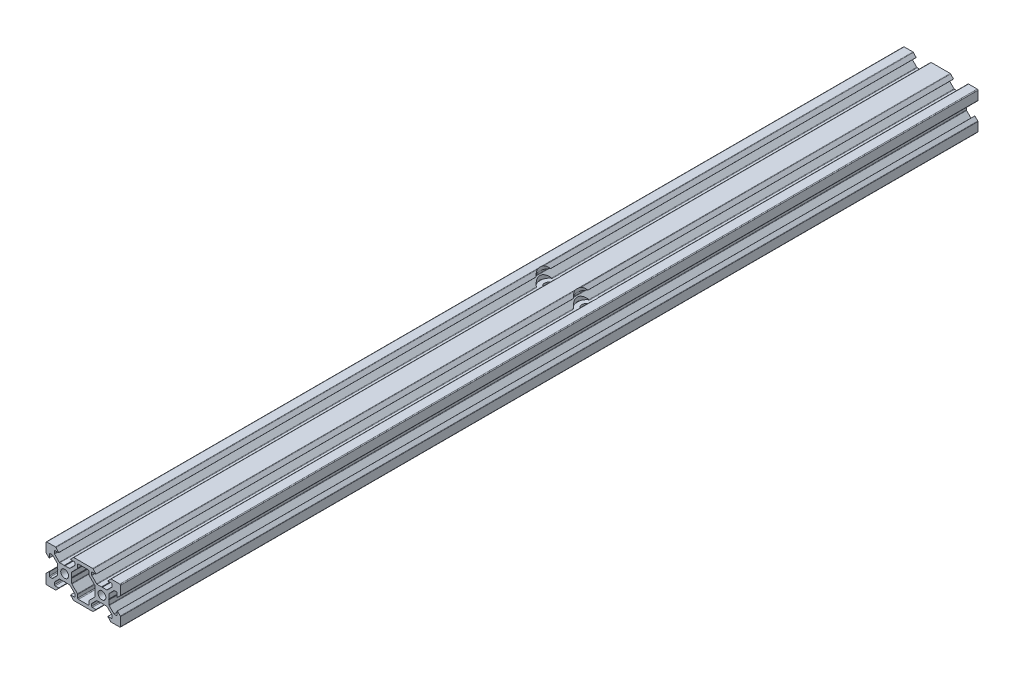
from build123d import *

# Parameters (mm, degrees)
SKETCH_1_R                  = 2
EXTRUDE_1_DEPTH             = 460
HOLE_WIZARD_5_0_5_1_D       = 5
HOLE_WIZARD_10_0_10_1_D     = 10
HOLE_WIZARD_10_0_10_1_DEPTH = 6.2
HOLE_WIZARD_M5_1_D          = 4.2
HOLE_WIZARD_M5_1_DEPTH      = 15
HOLE_WIZARD_M5_1_TIP        = 1.2618073
HOLE_WIZARD_M5_2_D          = 4.2
HOLE_WIZARD_M5_2_DEPTH      = 15
HOLE_WIZARD_M5_2_TIP        = 1.2618073


with BuildPart() as part:
    # 草图1 → 凸台-拉伸1 (new body)
    with BuildSketch(Plane.XY):
        with BuildLine():
            Line((0.2, 3.8), (2.573654403, 3.8))
            ThreePointArc((2.573654403, 3.8), (2.726727776, 3.830448187), (2.856497116, 3.917157288))
            Line((2.856497116, 3.917157288), (5.382842712, 6.443502884))
            ThreePointArc((5.382842712, 6.443502884), (5.469551813, 6.573272224), (5.5, 6.726345597))
            Line((5.5, 6.726345597), (5.5, 7.8))
            ThreePointArc((5.5, 7.8), (5.382842712, 8.082842712), (5.1, 8.2))
            Line((5.1, 8.2), (3.2, 8.2))
            Line((3.2, 8.2), (3.16812307, 8.273206881))
            Line((3.16812307, 8.273206881), (4.656346981, 9.872492278))
            ThreePointArc((4.656346981, 9.872492278), (4.789482475, 9.966740311), (4.949174504, 10))
            Line((4.949174504, 10), (10, 10))
            Line((10, 10), (15.050825496, 10))
            ThreePointArc((15.050825496, 10), (15.210517525, 9.966740311), (15.343653019, 9.872492278))
            Line((15.343653019, 9.872492278), (16.83187693, 8.273206881))
            Line((16.83187693, 8.273206881), (16.8, 8.2))
            Line((16.8, 8.2), (14.9, 8.2))
            ThreePointArc((14.9, 8.2), (14.617157288, 8.082842712), (14.5, 7.8))
            Line((14.5, 7.8), (14.5, 6.726345597))
            ThreePointArc((14.5, 6.726345597), (14.530448187, 6.573272224), (14.617157288, 6.443502884))
            Line((14.617157288, 6.443502884), (17.143502884, 3.917157288))
            ThreePointArc((17.143502884, 3.917157288), (17.273272224, 3.830448187), (17.426345597, 3.8))
            Line((17.426345597, 3.8), (19.8, 3.8))
            Line((19.8, 3.8), (20, 3.6))
            Line((20, 3.6), (20.2, 3.8))
            Line((20.2, 3.8), (22.573654403, 3.8))
            ThreePointArc((22.573654403, 3.8), (22.726727776, 3.830448187), (22.856497116, 3.917157288))
            Line((22.856497116, 3.917157288), (25.382842708, 6.44350288))
            ThreePointArc((25.382842708, 6.44350288), (25.469551809, 6.57327222), (25.499999996, 6.726345593))
            Line((25.499999996, 6.726345593), (25.499999996, 7.8))
            ThreePointArc((25.499999996, 7.8), (25.382842708, 8.082842712), (25.099999996, 8.2))
            Line((25.099999996, 8.2), (23.2, 8.2))
            Line((23.2, 8.2), (23.16812307, 8.273206881))
            Line((23.16812307, 8.273206881), (24.656346981, 9.872492278))
            ThreePointArc((24.656346981, 9.872492278), (24.789482475, 9.966740311), (24.949174504, 10))
            Line((24.949174504, 10), (29.6, 10))
            ThreePointArc((29.6, 10), (29.882842712, 9.882842712), (30, 9.6))
            Line((30, 9.6), (30, 4.949174504))
            ThreePointArc((30, 4.949174504), (29.966740311, 4.789482475), (29.872492278, 4.656346981))
            Line((29.872492278, 4.656346981), (28.273206881, 3.16812307))
            Line((28.273206881, 3.16812307), (28.2, 3.2))
            Line((28.2, 3.2), (28.2, 5.1))
            ThreePointArc((28.2, 5.1), (28.082842712, 5.382842712), (27.8, 5.5))
            Line((27.8, 5.5), (26.726345597, 5.5))
            ThreePointArc((26.726345597, 5.5), (26.573272224, 5.469551813), (26.443502884, 5.382842712))
            Line((26.443502884, 5.382842712), (23.917157288, 2.856497116))
            ThreePointArc((23.917157288, 2.856497116), (23.830448187, 2.726727776), (23.8, 2.573654403))
            Line((23.8, 2.573654403), (23.8, 0.2))
            Line((23.8, 0.2), (23.6, 0))
            Line((23.6, 0), (23.8, -0.2))
            Line((23.8, -0.2), (23.8, -2.573654403))
            ThreePointArc((23.8, -2.573654403), (23.830448187, -2.726727776), (23.917157288, -2.856497116))
            Line((23.917157288, -2.856497116), (26.443502884, -5.382842712))
            ThreePointArc((26.443502884, -5.382842712), (26.573272224, -5.469551813), (26.726345596, -5.5))
            Line((26.726345596, -5.5), (27.8, -5.500000002))
            ThreePointArc((27.8, -5.500000002), (28.082842712, -5.382842714), (28.2, -5.100000002))
            Line((28.2, -5.100000002), (28.2, -3.2))
            Line((28.2, -3.2), (28.273206881, -3.16812307))
            Line((28.273206881, -3.16812307), (29.872492278, -4.656346981))
            ThreePointArc((29.872492278, -4.656346981), (29.966740311, -4.789482475), (30, -4.949174504))
            Line((30, -4.949174504), (30, -9.6))
            ThreePointArc((30, -9.6), (29.882842712, -9.882842712), (29.6, -10))
            Line((29.6, -10), (24.949174504, -10))
            ThreePointArc((24.949174504, -10), (24.789482475, -9.966740311), (24.656346981, -9.872492278))
            Line((24.656346981, -9.872492278), (23.16812307, -8.273206881))
            Line((23.16812307, -8.273206881), (23.2, -8.2))
            Line((23.2, -8.2), (25.1, -8.2))
            ThreePointArc((25.1, -8.2), (25.382842712, -8.082842712), (25.5, -7.8))
            Line((25.5, -7.8), (25.5, -6.726345597))
            ThreePointArc((25.5, -6.726345597), (25.469551813, -6.573272224), (25.382842712, -6.443502884))
            Line((25.382842712, -6.443502884), (22.856497116, -3.917157288))
            ThreePointArc((22.856497116, -3.917157288), (22.726727776, -3.830448187), (22.573654403, -3.8))
            Line((22.573654403, -3.8), (20.2, -3.8))
            Line((20.2, -3.8), (20, -3.6))
            Line((20, -3.6), (19.8, -3.8))
            Line((19.8, -3.8), (17.426345597, -3.8))
            ThreePointArc((17.426345597, -3.8), (17.273272224, -3.830448187), (17.143502884, -3.917157288))
            Line((17.143502884, -3.917157288), (14.617157288, -6.443502884))
            ThreePointArc((14.617157288, -6.443502884), (14.530448187, -6.573272224), (14.5, -6.726345597))
            Line((14.5, -6.726345597), (14.5, -7.8))
            ThreePointArc((14.5, -7.8), (14.617157288, -8.082842712), (14.9, -8.2))
            Line((14.9, -8.2), (16.8, -8.2))
            Line((16.8, -8.2), (16.83187693, -8.273206881))
            Line((16.83187693, -8.273206881), (15.343653019, -9.872492278))
            ThreePointArc((15.343653019, -9.872492278), (15.210517525, -9.966740311), (15.050825496, -10))
            Line((15.050825496, -10), (10, -10))
            Line((10, -10), (4.949174504, -10))
            ThreePointArc((4.949174504, -10), (4.789482475, -9.966740311), (4.656346981, -9.872492278))
            Line((4.656346981, -9.872492278), (3.16812307, -8.273206881))
            Line((3.16812307, -8.273206881), (3.2, -8.2))
            Line((3.2, -8.2), (5.1, -8.2))
            ThreePointArc((5.1, -8.2), (5.382842713, -8.082842713), (5.5, -7.8))
            Line((5.5, -7.8), (5.5, -6.726345597))
            ThreePointArc((5.5, -6.726345597), (5.469551813, -6.573272224), (5.382842712, -6.443502884))
            Line((5.382842712, -6.443502884), (2.856497116, -3.917157288))
            ThreePointArc((2.856497116, -3.917157288), (2.726727776, -3.830448187), (2.573654403, -3.8))
            Line((2.573654403, -3.8), (0.2, -3.8))
            Line((0.2, -3.8), (0, -3.6))
            Line((0, -3.6), (-0.2, -3.8))
            Line((-0.2, -3.8), (-2.573654403, -3.8))
            ThreePointArc((-2.573654403, -3.8), (-2.726727776, -3.830448187), (-2.856497116, -3.917157288))
            Line((-2.856497116, -3.917157288), (-5.382842712, -6.443502884))
            ThreePointArc((-5.382842712, -6.443502884), (-5.469551813, -6.573272224), (-5.5, -6.726345597))
            Line((-5.5, -6.726345597), (-5.5, -7.8))
            ThreePointArc((-5.5, -7.8), (-5.382842712, -8.082842712), (-5.1, -8.2))
            Line((-5.1, -8.2), (-3.2, -8.2))
            Line((-3.2, -8.2), (-3.16812307, -8.273206881))
            Line((-3.16812307, -8.273206881), (-4.656346981, -9.872492278))
            ThreePointArc((-4.656346981, -9.872492278), (-4.789482475, -9.966740311), (-4.949174504, -10))
            Line((-4.949174504, -10), (-9.6, -10))
            ThreePointArc((-9.6, -10), (-9.882842712, -9.882842712), (-10, -9.6))
            Line((-10, -9.6), (-10, -4.949174504))
            ThreePointArc((-10, -4.949174504), (-9.966740311, -4.789482475), (-9.872492278, -4.656346981))
            Line((-9.872492278, -4.656346981), (-8.273206881, -3.16812307))
            Line((-8.273206881, -3.16812307), (-8.2, -3.2))
            Line((-8.2, -3.2), (-8.2, -5.100000002))
            ThreePointArc((-8.2, -5.100000002), (-8.082842712, -5.382842714), (-7.8, -5.500000002))
            Line((-7.8, -5.500000002), (-6.726345596, -5.5))
            ThreePointArc((-6.726345596, -5.5), (-6.573272223, -5.469551813), (-6.443502884, -5.382842712))
            Line((-6.443502884, -5.382842712), (-3.917157288, -2.856497116))
            ThreePointArc((-3.917157288, -2.856497116), (-3.830448187, -2.726727776), (-3.8, -2.573654403))
            Line((-3.8, -2.573654403), (-3.8, -0.2))
            Line((-3.8, -0.2), (-3.6, 0))
            Line((-3.6, 0), (-3.8, 0.2))
            Line((-3.8, 0.2), (-3.8, 2.573654403))
            ThreePointArc((-3.8, 2.573654403), (-3.830448187, 2.726727776), (-3.917157288, 2.856497116))
            Line((-3.917157288, 2.856497116), (-6.443502884, 5.382842712))
            ThreePointArc((-6.443502884, 5.382842712), (-6.573272224, 5.469551813), (-6.726345597, 5.5))
            Line((-6.726345597, 5.5), (-7.8, 5.5))
            ThreePointArc((-7.8, 5.5), (-8.082842712, 5.382842712), (-8.2, 5.1))
            Line((-8.2, 5.1), (-8.2, 3.2))
            Line((-8.2, 3.2), (-8.273206881, 3.16812307))
            Line((-8.273206881, 3.16812307), (-9.872492278, 4.656346981))
            ThreePointArc((-9.872492278, 4.656346981), (-9.966740311, 4.789482475), (-10, 4.949174504))
            Line((-10, 4.949174504), (-10, 9.6))
            ThreePointArc((-10, 9.6), (-9.882842712, 9.882842712), (-9.6, 10))
            Line((-9.6, 10), (-4.949174504, 10))
            ThreePointArc((-4.949174504, 10), (-4.789482475, 9.966740311), (-4.656346981, 9.872492278))
            Line((-4.656346981, 9.872492278), (-3.16812307, 8.273206881))
            Line((-3.16812307, 8.273206881), (-3.2, 8.2))
            Line((-3.2, 8.2), (-5.099999996, 8.2))
            ThreePointArc((-5.099999996, 8.2), (-5.382842708, 8.082842712), (-5.499999996, 7.8))
            Line((-5.499999996, 7.8), (-5.499999996, 6.726345593))
            ThreePointArc((-5.499999996, 6.726345593), (-5.469551809, 6.57327222), (-5.382842708, 6.44350288))
            Line((-5.382842708, 6.44350288), (-2.856497116, 3.917157288))
            ThreePointArc((-2.856497116, 3.917157288), (-2.726727776, 3.830448187), (-2.573654403, 3.8))
            Line((-2.573654403, 3.8), (-0.2, 3.8))
            Line((-0.2, 3.8), (0, 3.6))
            Line((0, 3.6), (0.2, 3.8))
        make_face()
        Circle(SKETCH_1_R, mode=Mode.SUBTRACT)
        with Locations((20, 0)):
            Circle(SKETCH_1_R, mode=Mode.SUBTRACT)
        with BuildLine():
            Line((3.8, 0.2), (3.8, 2.573654403))
            ThreePointArc((3.8, 2.573654403), (3.830448187, 2.726727776), (3.917157288, 2.856497116))
            Line((3.917157288, 2.856497116), (6.875280951, 5.81462078))
            ThreePointArc((6.875280951, 5.81462078), (6.967586575, 5.952765908), (7, 6.115719198))
            Line((7, 6.115719198), (7, 7.774182533))
            ThreePointArc((7, 7.774182533), (7.124719049, 8.075280951), (7.425817467, 8.2))
            Line((7.425817467, 8.2), (12.574182533, 8.2))
            ThreePointArc((12.574182533, 8.2), (12.875280951, 8.075280951), (13, 7.774182533))
            Line((13, 7.774182533), (13, 6.115719198))
            ThreePointArc((13, 6.115719198), (13.032413425, 5.952765908), (13.124719049, 5.81462078))
            Line((13.124719049, 5.81462078), (16.082842712, 2.856497116))
            ThreePointArc((16.082842712, 2.856497116), (16.169551813, 2.726727776), (16.2, 2.573654403))
            Line((16.2, 2.573654403), (16.2, 0.2))
            Line((16.2, 0.2), (16.4, 0))
            Line((16.4, 0), (16.2, -0.2))
            Line((16.2, -0.2), (16.2, -2.573654403))
            ThreePointArc((16.2, -2.573654403), (16.169551813, -2.726727776), (16.082842712, -2.856497116))
            Line((16.082842712, -2.856497116), (13.124719049, -5.81462078))
            ThreePointArc((13.124719049, -5.81462078), (13.032413425, -5.952765908), (13, -6.115719198))
            Line((13, -6.115719198), (13, -7.774182533))
            ThreePointArc((13, -7.774182533), (12.875280951, -8.075280951), (12.574182533, -8.2))
            Line((12.574182533, -8.2), (7.425817467, -8.2))
            ThreePointArc((7.425817467, -8.2), (7.124719049, -8.075280951), (7, -7.774182533))
            Line((7, -7.774182533), (7, -6.115719198))
            ThreePointArc((7, -6.115719198), (6.967586575, -5.952765908), (6.875280951, -5.81462078))
            Line((6.875280951, -5.81462078), (3.917157288, -2.856497116))
            ThreePointArc((3.917157288, -2.856497116), (3.830448187, -2.726727776), (3.8, -2.573654403))
            Line((3.8, -2.573654403), (3.8, -0.2))
            Line((3.8, -0.2), (3.6, 0))
            Line((3.6, 0), (3.8, 0.2))
        make_face(mode=Mode.SUBTRACT)
    extrude(amount=EXTRUDE_1_DEPTH)

    # Ø5.0 (5) 直径孔1 (through all)
    with Locations(Plane(origin=(0, 10, 0), x_dir=(1, 0, 0), z_dir=(0, 1, 0))):
        with Locations((20, -200), (0, -200)):
            Hole(HOLE_WIZARD_5_0_5_1_D / 2)

    # Ø10.0 (10) 直径孔1
    with Locations(Plane(origin=(0, 10, 0), x_dir=(1, 0, 0), z_dir=(0, 1, 0))):
        with Locations((20, -200), (0, -200)):
            Hole(HOLE_WIZARD_10_0_10_1_D / 2, depth=HOLE_WIZARD_10_0_10_1_DEPTH)

    # M5 螺纹孔1
    with Locations(Plane(origin=(0, 0, 0), x_dir=(-1, 0, 0), z_dir=(0, 0, -1))):
        with Locations((0, 0), (-20, 0)):
            Hole(HOLE_WIZARD_M5_1_D / 2, depth=HOLE_WIZARD_M5_1_DEPTH)
            with Locations((0, 0, -(HOLE_WIZARD_M5_1_DEPTH + HOLE_WIZARD_M5_1_TIP / 2))):  # 118° drill point
                Cone(0, HOLE_WIZARD_M5_1_D / 2, HOLE_WIZARD_M5_1_TIP, mode=Mode.SUBTRACT)

    # M5 螺纹孔2
    with Locations(Plane.XY.offset(460)):
        with Locations((0, 0), (20, 0)):
            Hole(HOLE_WIZARD_M5_2_D / 2, depth=HOLE_WIZARD_M5_2_DEPTH)
            with Locations((0, 0, -(HOLE_WIZARD_M5_2_DEPTH + HOLE_WIZARD_M5_2_TIP / 2))):  # 118° drill point
                Cone(0, HOLE_WIZARD_M5_2_D / 2, HOLE_WIZARD_M5_2_TIP, mode=Mode.SUBTRACT)


solid = part.part
